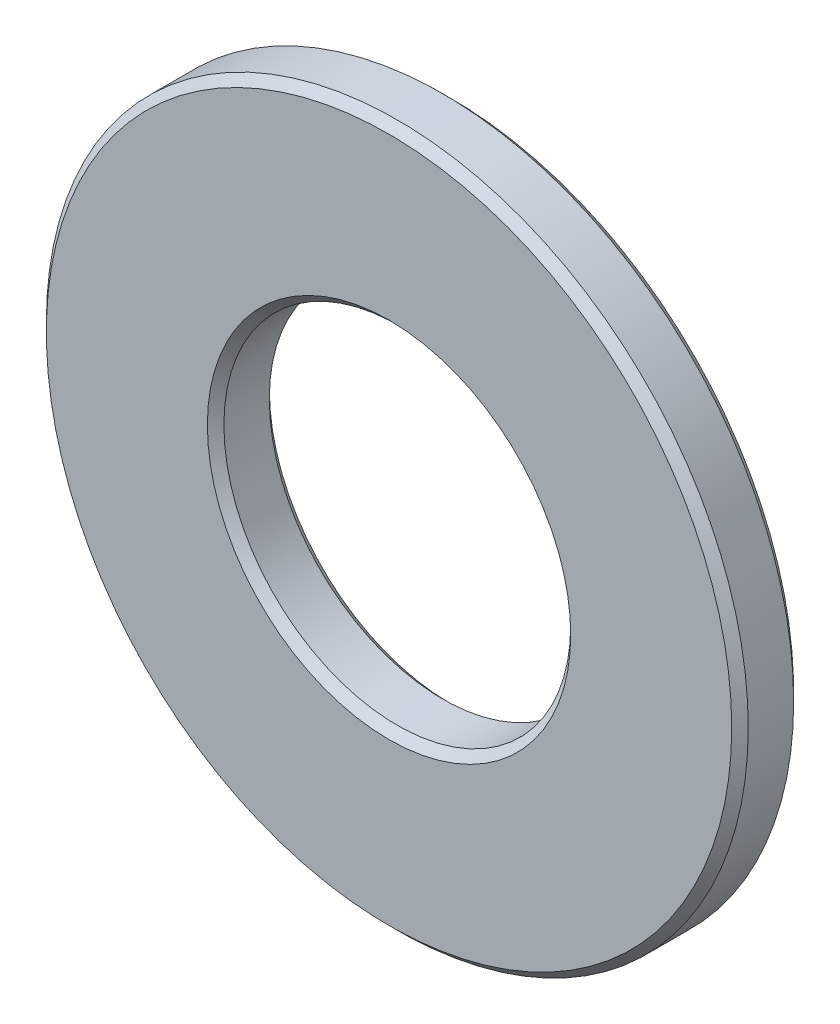
from build123d import *

# Parameters (mm, degrees)
SKETCH1_W     = 4.3
SKETCH1_H     = 1.5
CHAMFER1_SIZE = 0.2


with BuildPart() as part:
    # Sketch1 → Revolve1 (revolve)
    with BuildSketch(Plane(origin=(0, 0, 0), x_dir=(1, 0, 0), z_dir=(0, 1, 0))):
        with Locations((6.35, 0)):
            Rectangle(SKETCH1_W, SKETCH1_H)
    revolve(axis=Axis((0, 0, 0), (0, 0, -1)))

    # Chamfer1
    chamfer1_edges = [part.edges().sort_by_distance(p)[0] for p in [
        (-4.2, 0, -0.75),
        (-8.5, 0, -0.75),
        (-8.5, 0, 0.75),
        (-4.2, 0, 0.75),
    ]]
    chamfer(chamfer1_edges, length=CHAMFER1_SIZE)


solid = part.part
